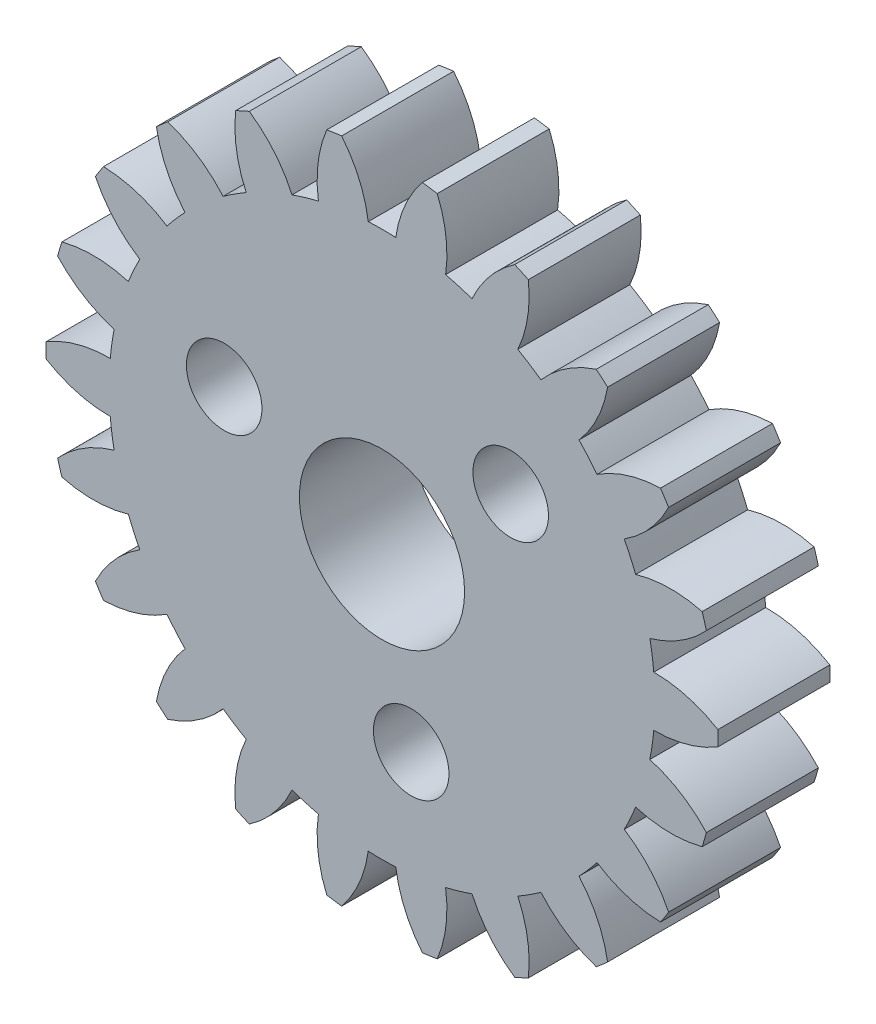
from build123d import *

# Parameters (mm, degrees)
MODEL_R             = 2.5
BOSS_EXTRUDE1_DEPTH = 4
SKETCH2_R           = 2.95
CUT_EXTRUDE1_DEPTH  = 4
SKETCH3_R           = 1.35
CUT_EXTRUDE2_DEPTH  = 4
CIRPATTERN1_COUNT   = 3


with BuildPart() as part:
    # Model → Boss-Extrude1 (new body)
    with BuildSketch(Plane.XY):
        with BuildLine():
            ThreePointArc((-11.997000624, 0.268283487), (-12, 0), (-11.997000624, -0.268283487))
            ThreePointArc((-11.997000624, -0.268283487), (-10.895606779, -0.741380557), (-9.707399683, -0.89966238))
            ThreePointArc((-9.707399683, -0.89966238), (-9.649769237, -1.387427358), (-9.56764597, -1.8716708))
            ThreePointArc((-9.56764597, -1.8716708), (-10.663129188, -2.358297721), (-11.586621996, -3.122529539))
            ThreePointArc((-11.586621996, -3.122529539), (-11.513915683, -3.380790682), (-11.43545361, -3.637361781))
            ThreePointArc((-11.43545361, -3.637361781), (-10.245387108, -3.780996591), (-9.060717605, -3.598110265))
            ThreePointArc((-9.060717605, -3.598110265), (-8.868002323, -4.049880962), (-8.652778483, -4.491372344))
            ThreePointArc((-8.652778483, -4.491372344), (-9.566788286, -5.266920743), (-10.237564162, -6.260373793))
            ThreePointArc((-10.237564162, -6.260373793), (-10.095042394, -6.487689809), (-9.947474154, -6.711762656))
            ThreePointArc((-9.947474154, -6.711762656), (-8.765147105, -6.514298768), (-7.679990073, -6.005060656))
            ThreePointArc((-7.679990073, -6.005060656), (-7.3678026, -6.384237295), (-7.036914342, -6.747209612))
            ThreePointArc((-7.036914342, -6.747209612), (-7.695403093, -7.74884917), (-8.059119765, -8.891039794))
            ThreePointArc((-8.059119765, -8.891039794), (-7.858328807, -9.068994892), (-7.653609502, -9.242416436))
            ThreePointArc((-7.653609502, -9.242416436), (-6.574807012, -8.719851201), (-5.67707542, -7.925516745))
            ThreePointArc((-5.67707542, -7.925516745), (-5.270707329, -8.201380692), (-4.850961252, -8.456428084))
            ThreePointArc((-4.850961252, -8.456428084), (-5.200582107, -9.603011921), (-5.227773414, -10.801406627))
            ThreePointArc((-5.227773414, -10.801406627), (-4.984980156, -10.915583944), (-4.739694926, -11.024304604))
            ThreePointArc((-4.739694926, -11.024304604), (-3.851815156, -10.218973149), (-3.214237879, -9.203894603))
            ThreePointArc((-3.214237879, -9.203894603), (-2.746610697, -9.354097), (-2.27201213, -9.480557045))
            ThreePointArc((-2.27201213, -9.480557045), (-2.284440889, -10.679195758), (-1.972903952, -11.836707735))
            ThreePointArc((-1.972903952, -11.836707735), (-1.707778059, -11.877857303), (-1.441798455, -11.913069177))
            ThreePointArc((-1.441798455, -11.913069177), (-0.816772145, -10.890214666), (-0.491001901, -9.736627657))
            ThreePointArc((-0.491001901, -9.736627657), (0, -9.749), (0.491001901, -9.736627657))
            ThreePointArc((0.491001901, -9.736627657), (0.816772145, -10.890214666), (1.441798455, -11.913069177))
            ThreePointArc((1.441798455, -11.913069177), (1.707778059, -11.877857303), (1.972903952, -11.836707735))
            ThreePointArc((1.972903952, -11.836707735), (2.284440889, -10.679195758), (2.27201213, -9.480557045))
            ThreePointArc((2.27201213, -9.480557045), (2.746610697, -9.354097), (3.214237879, -9.203894603))
            ThreePointArc((3.214237879, -9.203894603), (3.851815156, -10.218973149), (4.739694926, -11.024304604))
            ThreePointArc((4.739694926, -11.024304604), (4.984980156, -10.915583944), (5.227773414, -10.801406627))
            ThreePointArc((5.227773414, -10.801406627), (5.200582107, -9.603011921), (4.850961252, -8.456428084))
            ThreePointArc((4.850961252, -8.456428084), (5.270707329, -8.201380692), (5.67707542, -7.925516745))
            ThreePointArc((5.67707542, -7.925516745), (6.574807012, -8.719851201), (7.653609502, -9.242416436))
            ThreePointArc((7.653609502, -9.242416436), (7.858328807, -9.068994892), (8.059119765, -8.891039794))
            ThreePointArc((8.059119765, -8.891039794), (7.695403093, -7.74884917), (7.036914342, -6.747209612))
            ThreePointArc((7.036914342, -6.747209612), (7.3678026, -6.384237295), (7.679990073, -6.005060656))
            ThreePointArc((7.679990073, -6.005060656), (8.765147105, -6.514298768), (9.947474154, -6.711762656))
            ThreePointArc((9.947474154, -6.711762656), (10.095042394, -6.487689809), (10.237564162, -6.260373793))
            ThreePointArc((10.237564162, -6.260373793), (9.566788286, -5.266920743), (8.652778482, -4.491372344))
            ThreePointArc((8.652778482, -4.491372344), (8.868002323, -4.049880962), (9.060717605, -3.598110265))
            ThreePointArc((9.060717605, -3.598110265), (10.245387108, -3.780996591), (11.43545361, -3.637361781))
            ThreePointArc((11.43545361, -3.637361781), (11.513915683, -3.380790682), (11.586621996, -3.122529539))
            ThreePointArc((11.586621996, -3.122529539), (10.663129188, -2.358297721), (9.56764597, -1.8716708))
            ThreePointArc((9.56764597, -1.8716708), (9.649769237, -1.387427358), (9.707399683, -0.89966238))
            ThreePointArc((9.707399683, -0.89966238), (10.895606779, -0.741380557), (11.997000624, -0.268283487))
            ThreePointArc((11.997000624, -0.268283487), (12, 0), (11.997000624, 0.268283487))
            ThreePointArc((11.997000624, 0.268283487), (10.895606779, 0.741380557), (9.707399683, 0.89966238))
            ThreePointArc((9.707399683, 0.89966238), (9.649769237, 1.387427358), (9.56764597, 1.8716708))
            ThreePointArc((9.56764597, 1.8716708), (10.663129188, 2.358297721), (11.586621996, 3.122529539))
            ThreePointArc((11.586621996, 3.122529539), (11.513915683, 3.380790682), (11.43545361, 3.637361781))
            ThreePointArc((11.43545361, 3.637361781), (10.245387108, 3.780996591), (9.060717605, 3.598110265))
            ThreePointArc((9.060717605, 3.598110265), (8.868002323, 4.049880962), (8.652778483, 4.491372344))
            ThreePointArc((8.652778483, 4.491372344), (9.566788286, 5.266920743), (10.237564162, 6.260373793))
            ThreePointArc((10.237564162, 6.260373793), (10.095042394, 6.487689809), (9.947474154, 6.711762656))
            ThreePointArc((9.947474154, 6.711762656), (8.765147105, 6.514298768), (7.679990073, 6.005060656))
            ThreePointArc((7.679990073, 6.005060656), (7.3678026, 6.384237295), (7.036914342, 6.747209612))
            ThreePointArc((7.036914342, 6.747209612), (7.695403093, 7.74884917), (8.059119765, 8.891039794))
            ThreePointArc((8.059119765, 8.891039794), (7.858328807, 9.068994892), (7.653609502, 9.242416436))
            ThreePointArc((7.653609502, 9.242416436), (6.574807012, 8.719851201), (5.67707542, 7.925516745))
            ThreePointArc((5.67707542, 7.925516745), (5.270707329, 8.201380692), (4.850961252, 8.456428084))
            ThreePointArc((4.850961252, 8.456428084), (5.200582107, 9.603011921), (5.227773414, 10.801406627))
            ThreePointArc((5.227773414, 10.801406627), (4.984980156, 10.915583944), (4.739694926, 11.024304604))
            ThreePointArc((4.739694926, 11.024304604), (3.851815156, 10.218973149), (3.214237879, 9.203894603))
            ThreePointArc((3.214237879, 9.203894603), (2.746610697, 9.354097), (2.27201213, 9.480557045))
            ThreePointArc((2.27201213, 9.480557045), (2.284440889, 10.679195758), (1.972903952, 11.836707735))
            ThreePointArc((1.972903952, 11.836707735), (1.707778059, 11.877857303), (1.441798455, 11.913069177))
            ThreePointArc((1.441798455, 11.913069177), (0.816772145, 10.890214666), (0.491001901, 9.736627657))
            ThreePointArc((0.491001901, 9.736627657), (0, 9.749), (-0.491001901, 9.736627657))
            ThreePointArc((-0.491001901, 9.736627657), (-0.816772145, 10.890214666), (-1.441798455, 11.913069177))
            ThreePointArc((-1.441798455, 11.913069177), (-1.707778059, 11.877857303), (-1.972903952, 11.836707735))
            ThreePointArc((-1.972903952, 11.836707735), (-2.284440889, 10.679195758), (-2.27201213, 9.480557045))
            ThreePointArc((-2.27201213, 9.480557045), (-2.746610697, 9.354097), (-3.214237879, 9.203894603))
            ThreePointArc((-3.214237879, 9.203894603), (-3.851815156, 10.218973149), (-4.739694926, 11.024304604))
            ThreePointArc((-4.739694926, 11.024304604), (-4.984980156, 10.915583944), (-5.227773414, 10.801406627))
            ThreePointArc((-5.227773414, 10.801406627), (-5.200582107, 9.603011921), (-4.850961252, 8.456428084))
            ThreePointArc((-4.850961252, 8.456428084), (-5.270707329, 8.201380692), (-5.67707542, 7.925516745))
            ThreePointArc((-5.67707542, 7.925516745), (-6.574807012, 8.719851201), (-7.653609502, 9.242416436))
            ThreePointArc((-7.653609502, 9.242416436), (-7.858328807, 9.068994892), (-8.059119765, 8.891039794))
            ThreePointArc((-8.059119765, 8.891039794), (-7.695403093, 7.74884917), (-7.036914342, 6.747209612))
            ThreePointArc((-7.036914342, 6.747209612), (-7.3678026, 6.384237295), (-7.679990073, 6.005060656))
            ThreePointArc((-7.679990073, 6.005060656), (-8.765147105, 6.514298768), (-9.947474154, 6.711762656))
            ThreePointArc((-9.947474154, 6.711762656), (-10.095042394, 6.487689809), (-10.237564162, 6.260373793))
            ThreePointArc((-10.237564162, 6.260373793), (-9.566788286, 5.266920743), (-8.652778482, 4.491372344))
            ThreePointArc((-8.652778482, 4.491372344), (-8.868002323, 4.049880962), (-9.060717605, 3.598110265))
            ThreePointArc((-9.060717605, 3.598110265), (-10.245387108, 3.780996591), (-11.43545361, 3.637361781))
            ThreePointArc((-11.43545361, 3.637361781), (-11.513915683, 3.380790682), (-11.586621996, 3.122529539))
            ThreePointArc((-11.586621996, 3.122529539), (-10.663129188, 2.358297721), (-9.56764597, 1.8716708))
            ThreePointArc((-9.56764597, 1.8716708), (-9.649769237, 1.387427358), (-9.707399683, 0.89966238))
            ThreePointArc((-9.707399683, 0.89966238), (-10.895606779, 0.741380557), (-11.997000624, 0.268283487))
        make_face()
        Circle(MODEL_R, mode=Mode.SUBTRACT)
    extrude(amount=BOSS_EXTRUDE1_DEPTH)

    # Sketch2 → Cut-Extrude1 (cut)
    with BuildSketch(Plane.XY.offset(4)):
        Circle(SKETCH2_R)
    extrude(amount=-CUT_EXTRUDE1_DEPTH, mode=Mode.SUBTRACT)

    # Sketch3 → Cut-Extrude2 (cut)
    with BuildSketch(Plane.XY.offset(4)):
        with Locations((-5.638155725, 2.05212086)):
            Circle(SKETCH3_R)
    cut_extrude2 = extrude(amount=-CUT_EXTRUDE2_DEPTH, mode=Mode.SUBTRACT)

    # CirPattern1: Cut-Extrude2 ×3 about axis
    cirpattern1_axis = Axis((0, 0, 0), (0, 0, 1))
    for i in range(1, CIRPATTERN1_COUNT):
        add(cut_extrude2.rotate(cirpattern1_axis, i * 360 / CIRPATTERN1_COUNT), mode=Mode.SUBTRACT)


solid = part.part
